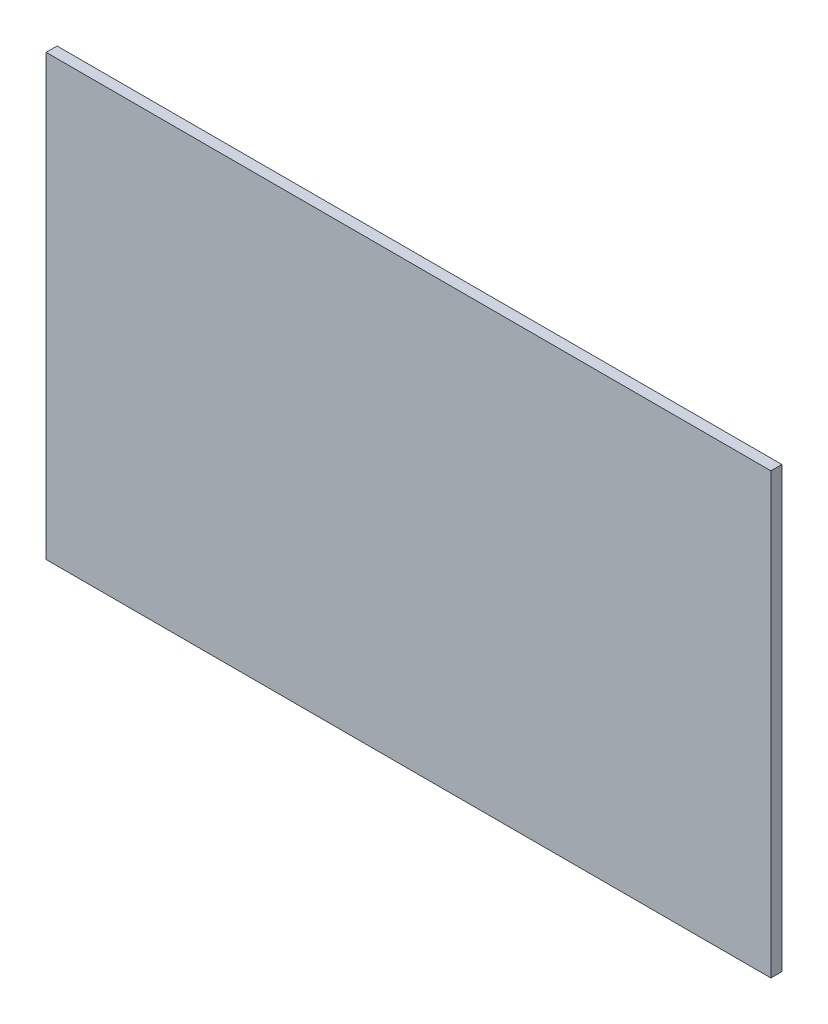
from build123d import *

# Parameters (mm, degrees)
SKETCH1_W           = 5029.2
SKETCH1_H           = 3048
BOSS_EXTRUDE1_DEPTH = 76.2


with BuildPart() as part:
    # Sketch1 → Boss-Extrude1 (new body)
    with BuildSketch(Plane.XY):
        with Locations((2514.6, 1524)):
            Rectangle(SKETCH1_W, SKETCH1_H)
    extrude(amount=BOSS_EXTRUDE1_DEPTH)


solid = part.part
